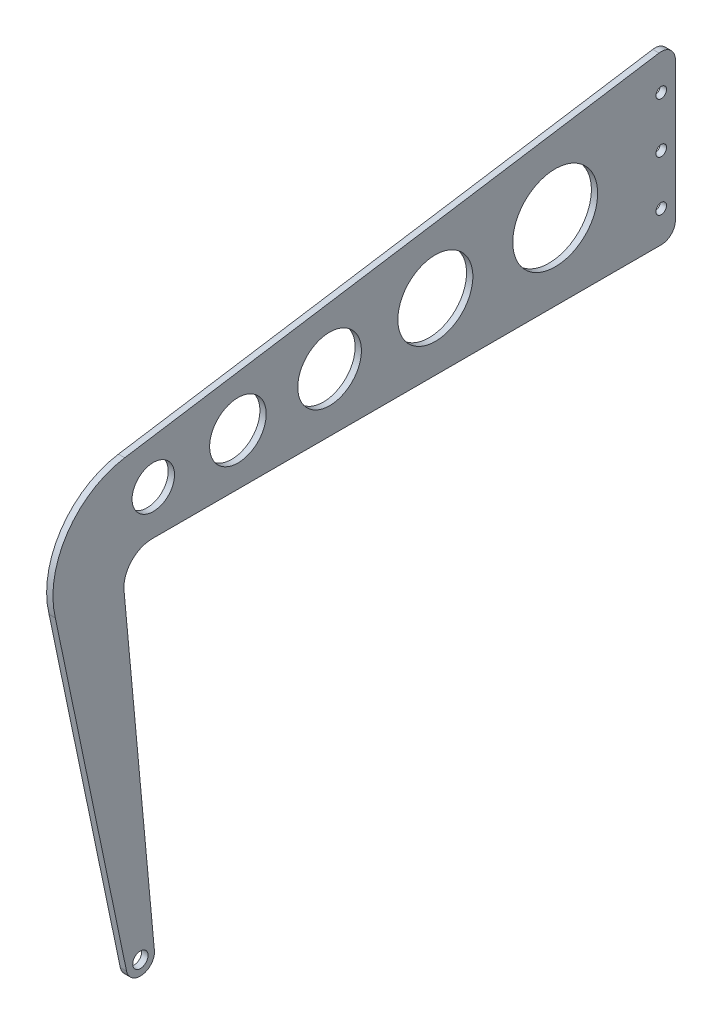
from build123d import *

# Parameters (mm, degrees)
SKETCH1_R           = 21.453903958
SKETCH1_R_2         = 28.605205278
SKETCH1_R_3         = 32.180855938
SKETCH1_R_4         = 37.901896993
SKETCH1_R_5         = 42.907807917
SKETCH1_R_6         = 5.36347599
SKETCH1_R_7         = 7.721787304
BOSS_EXTRUDE1_DEPTH = 6.35


with BuildPart() as part:
    # Sketch1 → Boss-Extrude1 (new body)
    with BuildSketch(Plane(origin=(6.35, 0, 0), x_dir=(0, 0, -1), z_dir=(1, 0, 0))):
        with BuildLine():
            Line((0, 14.302602639), (0, 154.924676439))
            ThreePointArc((0, 154.924676439), (-5.001080355, 165.789579819), (-16.506943305, 169.05638987))
            Line((-16.506943305, 169.05638987), (-556.724944278, 84.790280581))
            ThreePointArc((-556.724944278, 84.790280581), (-614.910173951, 47.589388665), (-626.846614509, -20.432289484))
            Line((-626.846614509, -20.432289484), (-554.875036537, -365.59476496))
            ThreePointArc((-554.875036537, -365.59476496), (-537.95714064, -376.674692686), (-526.877212914, -359.756796789))
            Line((-526.877212914, -359.756796789), (-557.365265272, -31.595263427))
            ThreePointArc((-557.365265272, -31.595263427), (-550.174572585, -9.464586925), (-528.916762301, 0))
            Line((-528.916762301, 0), (-14.302602639, 0))
            ThreePointArc((-14.302602639, 0), (-4.189135324, 4.189135324), (0, 14.302602639))
        make_face()
        with Locations((-527.810296047, 44.736567742)):
            Circle(SKETCH1_R, mode=Mode.SUBTRACT)
        with Locations((-442.267958292, 51.579693661)):
            Circle(SKETCH1_R_2, mode=Mode.SUBTRACT)
        with Locations((-349.597092391, 58.993080074)):
            Circle(SKETCH1_R_3, mode=Mode.SUBTRACT)
        with Locations((-242.669170198, 67.546987473)):
            Circle(SKETCH1_R_4, mode=Mode.SUBTRACT)
        with Locations((-121.484191712, 77.241415858)):
            Circle(SKETCH1_R_5, mode=Mode.SUBTRACT)
        with Locations((-14.302602639, 133.35)):
            Circle(SKETCH1_R_6, mode=Mode.SUBTRACT)
        with Locations((-14.302602639, 82.55)):
            Circle(SKETCH1_R_6, mode=Mode.SUBTRACT)
        with Locations((-14.302602639, 31.75)):
            Circle(SKETCH1_R_6, mode=Mode.SUBTRACT)
        with Locations((-540.876124725, -362.675780874)):
            Circle(SKETCH1_R_7, mode=Mode.SUBTRACT)
    extrude(amount=-BOSS_EXTRUDE1_DEPTH)


solid = part.part
